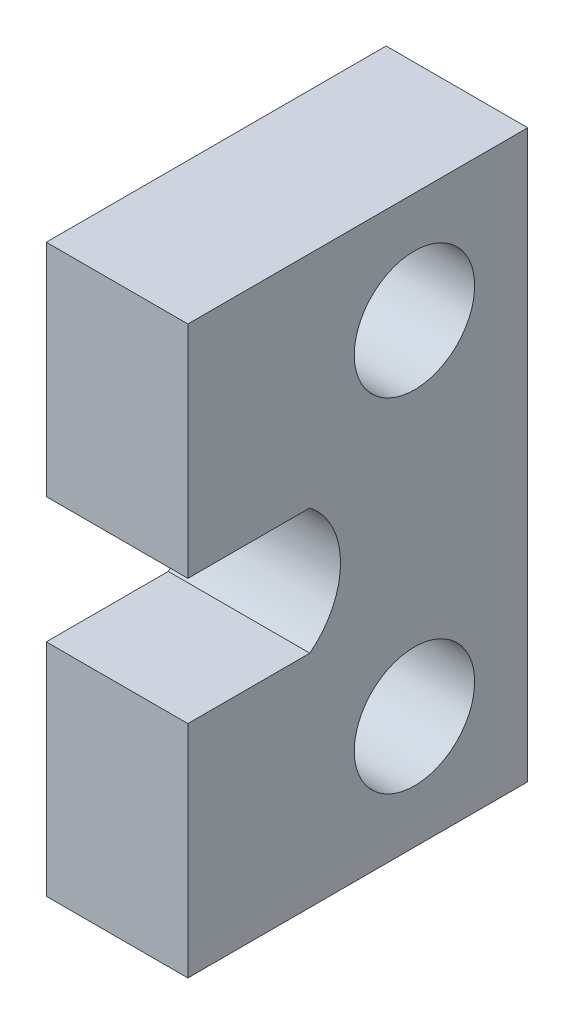
from build123d import *

# Parameters (mm, degrees)
SKETCH1_W           = 15.875
SKETCH1_H           = 63.5
BOSS_EXTRUDE1_DEPTH = 38.1
CUT_EXTRUDE1_DEPTH  = 16.875
SKETCH3_R           = 6.746875
CUT_EXTRUDE2_DEPTH  = 16.875


with BuildPart() as part:
    # Sketch1 → Boss-Extrude1 (new body)
    with BuildSketch(Plane.XY):
        with Locations((7.9375, 31.75)):
            Rectangle(SKETCH1_W, SKETCH1_H)
    extrude(amount=BOSS_EXTRUDE1_DEPTH)

    # Sketch2 → Cut-Extrude1 (cut, through all)
    with BuildSketch(Plane.ZY):
        with BuildLine():
            ThreePointArc((24.4280023, 38.7985), (20.984165451, 31.75), (24.4280023, 24.7015))
            Line((24.4280023, 24.7015), (38.1, 24.7015))
            Line((38.1, 24.7015), (38.1, 38.7985))
            Line((38.1, 38.7985), (24.4280023, 38.7985))
        make_face()
    extrude(amount=-CUT_EXTRUDE1_DEPTH, mode=Mode.SUBTRACT)

    # Sketch3 → Cut-Extrude2 (cut, through all)
    with BuildSketch(Plane.ZY):
        with Locations((12.7, 51.14925)):
            Circle(SKETCH3_R)
        with Locations((12.7, 12.7)):
            Circle(SKETCH3_R)
    extrude(amount=-CUT_EXTRUDE2_DEPTH, mode=Mode.SUBTRACT)


solid = part.part
